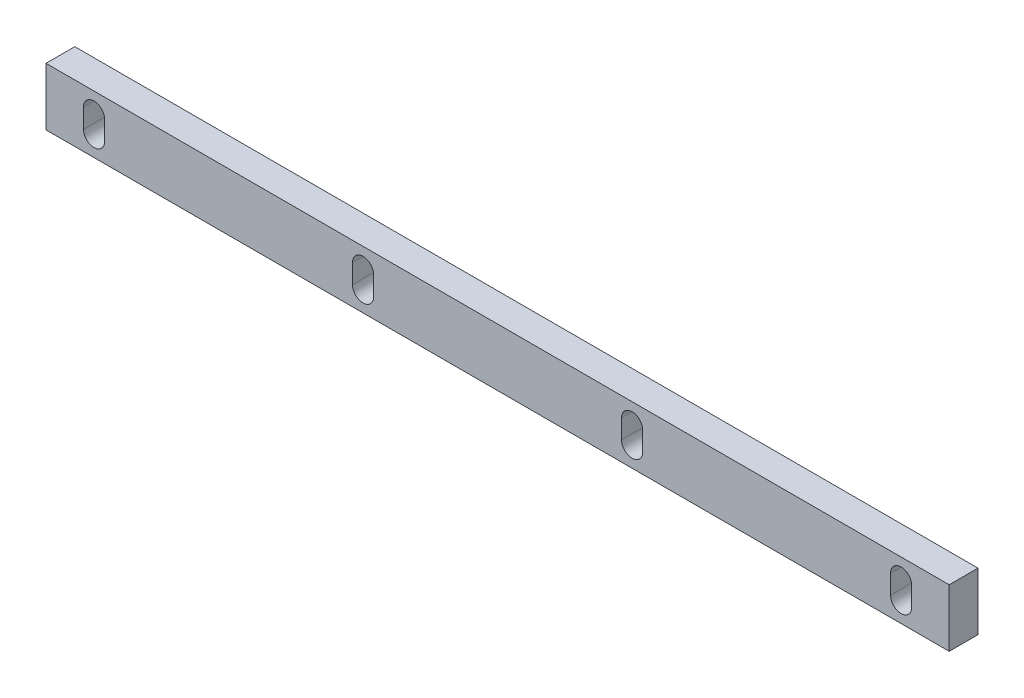
from build123d import *

# Parameters (mm, degrees)
PLAT_W                      = 30
PLAT_H                      = 15
EL_MENT_M_CANO_SOUD_1_DEPTH = 470
ENL_V_MAT_EXTRU_2_DEPTH     = 20
R_P_TITION_LIN_AIRE1_COUNT  = 4
R_P_TITION_LIN_AIRE1_PITCH  = 140


with BuildPart() as part:
    # plat → Elément mécano-soudé1 (new body)
    with BuildSketch(Plane.YZ.offset(-235)):
        Rectangle(PLAT_W, PLAT_H)
    extrude(amount=EL_MENT_M_CANO_SOUD_1_DEPTH)

    # Esquisse7 → Enlèv. mat.-Extru.2 (cut)
    with BuildSketch(Plane.XY.offset(7.5)):
        with BuildLine():
            Line((-215.5, -5), (-215.5, 5))
            ThreePointArc((-215.5, 5), (-210, 10.5), (-204.5, 5))
            Line((-204.5, 5), (-204.5, -5))
            ThreePointArc((-204.5, -5), (-210, -10.5), (-215.5, -5))
        make_face()
    enl_v_mat_extru_2 = extrude(amount=-ENL_V_MAT_EXTRU_2_DEPTH, mode=Mode.SUBTRACT)

    # Répétition linéaire1: Enlèv. mat.-Extru.2 ×4
    with Locations(*[(i * R_P_TITION_LIN_AIRE1_PITCH, 0, 0) for i in range(1, R_P_TITION_LIN_AIRE1_COUNT)]):
        add(enl_v_mat_extru_2, mode=Mode.SUBTRACT)


solid = part.part
